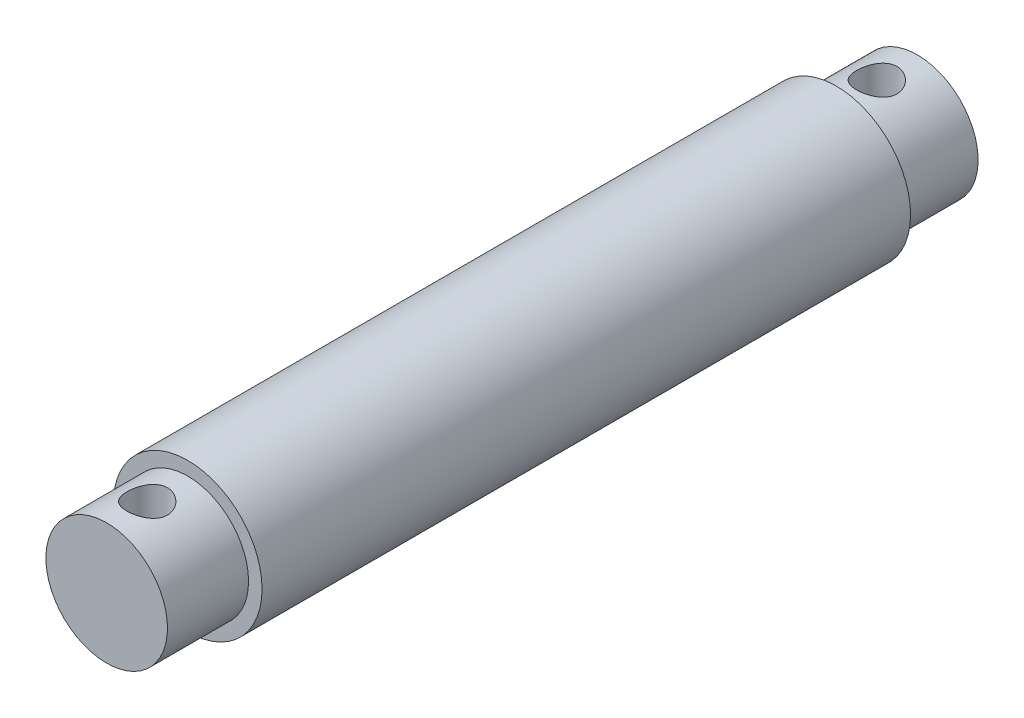
from build123d import *

# Parameters (mm, degrees)
SKETCH1_R               = 5.5
BOSS_EXTRUDE1_DEPTH     = 48
SKETCH2_R               = 4.5
BOSS_EXTRUDE2_DEPTH     = 6
SKETCH3_R               = 4.5
BOSS_EXTRUDE3_DEPTH     = 6
SKETCH4_R               = 1.5
CUT_EXTRUDE1_DEPTH      = 6.5
CUT_EXTRUDE1_DEPTH_BACK = 6.5


with BuildPart() as part:
    # Sketch1 → Boss-Extrude1 (new body)
    with BuildSketch(Plane.XY):
        Circle(SKETCH1_R)
    extrude(amount=BOSS_EXTRUDE1_DEPTH)

    # Sketch2 → Boss-Extrude2 (add)
    with BuildSketch(Plane.XY.offset(48)):
        Circle(SKETCH2_R)
    extrude(amount=BOSS_EXTRUDE2_DEPTH)

    # Sketch3 → Boss-Extrude3 (add)
    with BuildSketch(Plane(origin=(0, 0, 0), x_dir=(-1, 0, 0), z_dir=(0, 0, -1))):
        Circle(SKETCH3_R)
    extrude(amount=BOSS_EXTRUDE3_DEPTH)

    # Sketch4 → Cut-Extrude1 (cut, two sides)
    with BuildSketch(Plane(origin=(0, 0, 0), x_dir=(1, 0, 0), z_dir=(0, 1, 0))) as cut_extrude1_sk:
        with Locations((0, 3)):
            Circle(SKETCH4_R)
        with Locations((0, -51)):
            Circle(SKETCH4_R)
    extrude(amount=CUT_EXTRUDE1_DEPTH, mode=Mode.SUBTRACT)
    extrude(cut_extrude1_sk.sketch, amount=-CUT_EXTRUDE1_DEPTH_BACK, mode=Mode.SUBTRACT)


solid = part.part
